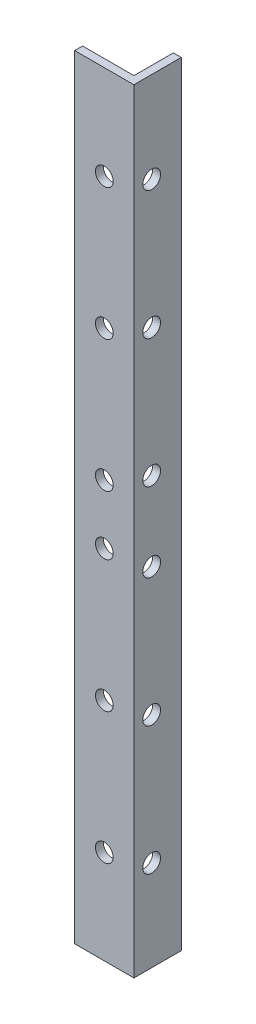
from build123d import *

# Parameters (mm, degrees)
BOSS_EXTRUDE1_DEPTH = 196
CUT_EXTRUDE4_REACH  = 17
SKETCH5_R           = 2.25
CUT_EXTRUDE5_REACH  = 14
SKETCH6_R           = 2.25


with BuildPart() as part:
    # Sketch1 → Boss-Extrude1 (new body)
    with BuildSketch(Plane(origin=(0, 0, 0), x_dir=(1, 0, 0), z_dir=(0, 1, 0))):
        Polygon((0, 0), (15, 0), (15, 12), (13, 12), (13, 2), (0, 2), align=None)
    extrude(amount=BOSS_EXTRUDE1_DEPTH)

    # Sketch5 → Cut-Extrude4 (cut, up to next)
    with BuildSketch(Plane(origin=(15, 0, 0), x_dir=(0, 0, -1), z_dir=(1, 0, 0)), mode=Mode.PRIVATE) as cut_extrude4_sk1:
        with Locations((4.5, 23)):
            Circle(SKETCH5_R)
    cut_extrude4_tool1 = extrude(cut_extrude4_sk1.sketch, amount=-CUT_EXTRUDE4_REACH, mode=Mode.PRIVATE) & part.part
    add(cut_extrude4_tool1.solids().sort_by_distance((15, 23, -4.5))[0], mode=Mode.SUBTRACT)
    # Sketch5 → Cut-Extrude4 (cut, up to next)
    with BuildSketch(Plane(origin=(15, 0, 0), x_dir=(0, 0, -1), z_dir=(1, 0, 0)), mode=Mode.PRIVATE) as cut_extrude4_sk2:
        with Locations((4.5, 55.5)):
            Circle(SKETCH5_R)
    cut_extrude4_tool2 = extrude(cut_extrude4_sk2.sketch, amount=-CUT_EXTRUDE4_REACH, mode=Mode.PRIVATE) & part.part
    add(cut_extrude4_tool2.solids().sort_by_distance((15, 55.5, -4.5))[0], mode=Mode.SUBTRACT)
    # Sketch5 → Cut-Extrude4 (cut, up to next)
    with BuildSketch(Plane(origin=(15, 0, 0), x_dir=(0, 0, -1), z_dir=(1, 0, 0)), mode=Mode.PRIVATE) as cut_extrude4_sk3:
        with Locations((4.5, 88)):
            Circle(SKETCH5_R)
    cut_extrude4_tool3 = extrude(cut_extrude4_sk3.sketch, amount=-CUT_EXTRUDE4_REACH, mode=Mode.PRIVATE) & part.part
    add(cut_extrude4_tool3.solids().sort_by_distance((15, 88, -4.5))[0], mode=Mode.SUBTRACT)
    # Sketch5 → Cut-Extrude4 (cut, up to next)
    with BuildSketch(Plane(origin=(15, 0, 0), x_dir=(0, 0, -1), z_dir=(1, 0, 0)), mode=Mode.PRIVATE) as cut_extrude4_sk4:
        with Locations((4.5, 108)):
            Circle(SKETCH5_R)
    cut_extrude4_tool4 = extrude(cut_extrude4_sk4.sketch, amount=-CUT_EXTRUDE4_REACH, mode=Mode.PRIVATE) & part.part
    add(cut_extrude4_tool4.solids().sort_by_distance((15, 108, -4.5))[0], mode=Mode.SUBTRACT)
    # Sketch5 → Cut-Extrude4 (cut, up to next)
    with BuildSketch(Plane(origin=(15, 0, 0), x_dir=(0, 0, -1), z_dir=(1, 0, 0)), mode=Mode.PRIVATE) as cut_extrude4_sk5:
        with Locations((4.5, 140.5)):
            Circle(SKETCH5_R)
    cut_extrude4_tool5 = extrude(cut_extrude4_sk5.sketch, amount=-CUT_EXTRUDE4_REACH, mode=Mode.PRIVATE) & part.part
    add(cut_extrude4_tool5.solids().sort_by_distance((15, 140.5, -4.5))[0], mode=Mode.SUBTRACT)
    # Sketch5 → Cut-Extrude4 (cut, up to next)
    with BuildSketch(Plane(origin=(15, 0, 0), x_dir=(0, 0, -1), z_dir=(1, 0, 0)), mode=Mode.PRIVATE) as cut_extrude4_sk6:
        with Locations((4.5, 173)):
            Circle(SKETCH5_R)
    cut_extrude4_tool6 = extrude(cut_extrude4_sk6.sketch, amount=-CUT_EXTRUDE4_REACH, mode=Mode.PRIVATE) & part.part
    add(cut_extrude4_tool6.solids().sort_by_distance((15, 173, -4.5))[0], mode=Mode.SUBTRACT)

    # Sketch6 → Cut-Extrude5 (cut, up to next)
    with BuildSketch(Plane.XY, mode=Mode.PRIVATE) as cut_extrude5_sk1:
        with Locations((7.5, 23.833333333)):
            Circle(SKETCH6_R)
    cut_extrude5_tool1 = extrude(cut_extrude5_sk1.sketch, amount=-CUT_EXTRUDE5_REACH, mode=Mode.PRIVATE) & part.part
    add(cut_extrude5_tool1.solids().sort_by_distance((7.5, 23.833333, 0))[0], mode=Mode.SUBTRACT)
    # Sketch6 → Cut-Extrude5 (cut, up to next)
    with BuildSketch(Plane.XY, mode=Mode.PRIVATE) as cut_extrude5_sk2:
        with Locations((7.5, 57.166666667)):
            Circle(SKETCH6_R)
    cut_extrude5_tool2 = extrude(cut_extrude5_sk2.sketch, amount=-CUT_EXTRUDE5_REACH, mode=Mode.PRIVATE) & part.part
    add(cut_extrude5_tool2.solids().sort_by_distance((7.5, 57.166667, 0))[0], mode=Mode.SUBTRACT)
    # Sketch6 → Cut-Extrude5 (cut, up to next)
    with BuildSketch(Plane.XY, mode=Mode.PRIVATE) as cut_extrude5_sk3:
        with Locations((7.5, 90.5)):
            Circle(SKETCH6_R)
    cut_extrude5_tool3 = extrude(cut_extrude5_sk3.sketch, amount=-CUT_EXTRUDE5_REACH, mode=Mode.PRIVATE) & part.part
    add(cut_extrude5_tool3.solids().sort_by_distance((7.5, 90.5, 0))[0], mode=Mode.SUBTRACT)
    # Sketch6 → Cut-Extrude5 (cut, up to next)
    with BuildSketch(Plane.XY, mode=Mode.PRIVATE) as cut_extrude5_sk4:
        with Locations((7.5, 105.5)):
            Circle(SKETCH6_R)
    cut_extrude5_tool4 = extrude(cut_extrude5_sk4.sketch, amount=-CUT_EXTRUDE5_REACH, mode=Mode.PRIVATE) & part.part
    add(cut_extrude5_tool4.solids().sort_by_distance((7.5, 105.5, 0))[0], mode=Mode.SUBTRACT)
    # Sketch6 → Cut-Extrude5 (cut, up to next)
    with BuildSketch(Plane.XY, mode=Mode.PRIVATE) as cut_extrude5_sk5:
        with Locations((7.5, 138.833333333)):
            Circle(SKETCH6_R)
    cut_extrude5_tool5 = extrude(cut_extrude5_sk5.sketch, amount=-CUT_EXTRUDE5_REACH, mode=Mode.PRIVATE) & part.part
    add(cut_extrude5_tool5.solids().sort_by_distance((7.5, 138.833333, 0))[0], mode=Mode.SUBTRACT)
    # Sketch6 → Cut-Extrude5 (cut, up to next)
    with BuildSketch(Plane.XY, mode=Mode.PRIVATE) as cut_extrude5_sk6:
        with Locations((7.5, 172.166666667)):
            Circle(SKETCH6_R)
    cut_extrude5_tool6 = extrude(cut_extrude5_sk6.sketch, amount=-CUT_EXTRUDE5_REACH, mode=Mode.PRIVATE) & part.part
    add(cut_extrude5_tool6.solids().sort_by_distance((7.5, 172.166667, 0))[0], mode=Mode.SUBTRACT)


solid = part.part
